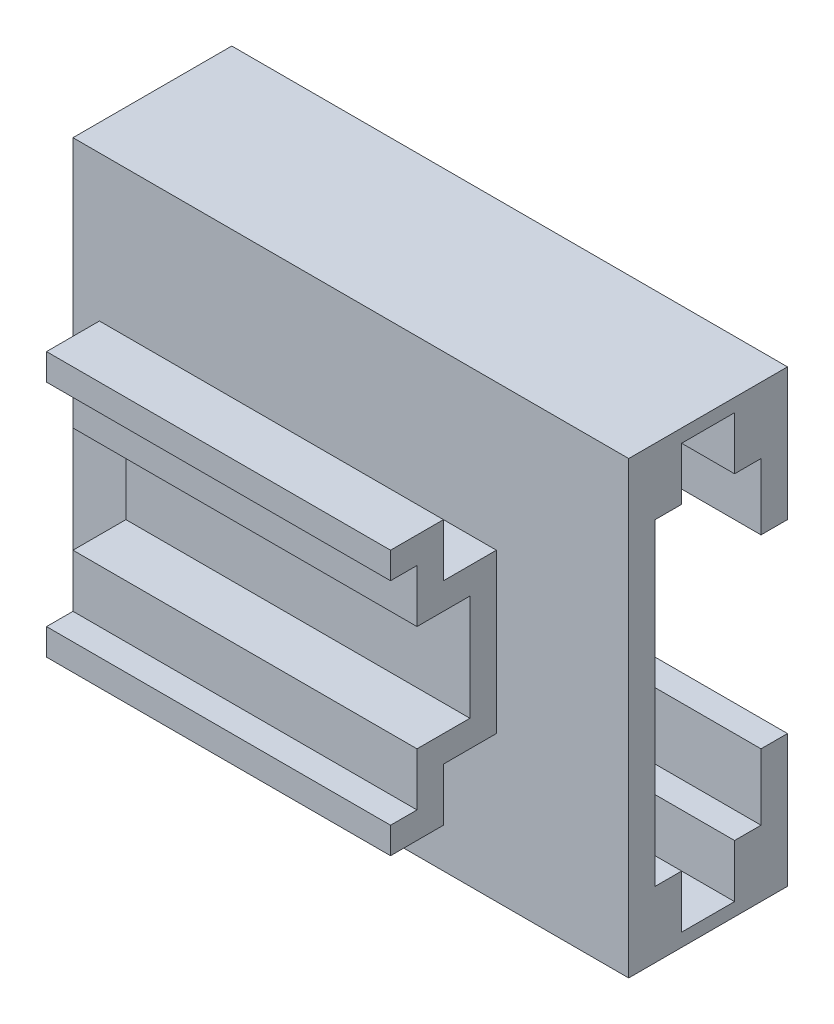
from build123d import *

# Parameters (mm, degrees)
ESQUISSE1_W             = 21
ESQUISSE1_H             = 17
BOSS_EXTRU_1_DEPTH      = 1
BOSS_EXTRU_2_START      = -4
BOSS_EXTRU_2_DEPTH      = 1
ESQUISSE1_4_W           = 21
ESQUISSE1_4_H           = 2.5
BOSS_EXTRU_3_DEPTH      = 4
ENL_V_START             = -1
ESQUISSE1_6_W           = 19.5
ESQUISSE1_6_H           = 2
ENL_V_MAT_EXTRU_1_DEPTH = 2
BOSS_EXTRU_4_START      = -3
BOSS_EXTRU_4_DEPTH      = 13


with BuildPart() as part:
    # Esquisse1 → Boss.-Extru.1 (new body)
    with BuildSketch(Plane.XY):
        Rectangle(ESQUISSE1_W, ESQUISSE1_H)
    extrude(amount=BOSS_EXTRU_1_DEPTH)



with BuildPart() as body_2:
    # Esquisse1_3 → Boss.-Extru.2 (new body)
    with BuildSketch(Plane.XY.offset(BOSS_EXTRU_2_START)):
        Polygon((-10.5, 8.5), (-10.5, -8.5), (10.5, -8.5), (10.5, -3.5), (-1, -3.5), (-1, 3.5), (10.5, 3.5), (10.5, 8.5), align=None)
    extrude(amount=-BOSS_EXTRU_2_DEPTH)


with BuildPart() as part_1:
    add(part.part)

    add(body_2.part)  # Boss.-Extru.3 merges body 2
    # Esquisse1_4 → Boss.-Extru.3 (add)
    with BuildSketch(Plane.XY):
        with Locations((0, 7.25)):
            Rectangle(ESQUISSE1_4_W, ESQUISSE1_4_H)
        with Locations((0, -7.25)):
            Rectangle(ESQUISSE1_4_W, ESQUISSE1_4_H)
    extrude(amount=-BOSS_EXTRU_3_DEPTH)

    # Esquisse1_6 → Enl_v. mat.-Extru.1 (cut)
    with BuildSketch(Plane.XY.offset(ENL_V_START)):
        with Locations((0.75, -7)):
            Rectangle(ESQUISSE1_6_W, ESQUISSE1_6_H)
        with Locations((0.75, 7)):
            Rectangle(ESQUISSE1_6_W, ESQUISSE1_6_H)
    extrude(amount=-ENL_V_MAT_EXTRU_1_DEPTH, mode=Mode.SUBTRACT)

    # Esquisse2 → Boss.-Extru.4 (add)
    with BuildSketch(Plane.ZY.offset(10.5).offset(BOSS_EXTRU_4_START)):
        Polygon((3, 3), (1, 3), (1, -3), (3, -3), (3, -5), (5, -5), (5, -4), (4, -4), (4, -2), (2, -2), (2, 2), (4, 2), (4, 4), (5, 4), (5, 5), (3, 5), align=None)
    extrude(amount=-BOSS_EXTRU_4_DEPTH)


solid = part_1.part
